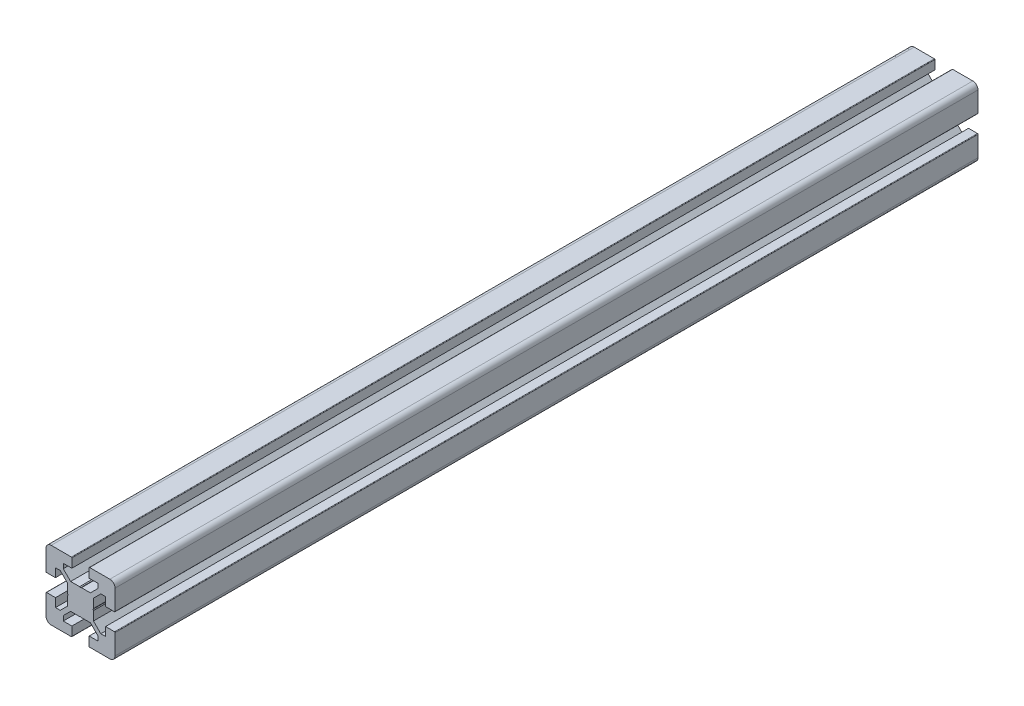
from build123d import *

# Parameters (mm, degrees)
EXTRUDE_1_DEPTH = 500


with BuildPart() as part:
    # Model → ﾎﾞｽ - 押し出し1 (new body)
    with BuildSketch(Plane.XY):
        with BuildLine():
            Line((69.700000053, 55.000000195), (64.500000711, 55.000000195))
            Line((64.500000711, 55.000000195), (64.500000711, 60.000002187))
            Line((64.500000711, 60.000002187), (61.76777021, 60.000002187))
            Line((61.76777021, 60.000002187), (57.500000584, 55.732232559))
            Line((57.500000584, 55.732232559), (57.500000584, 50.519614724))
            Line((57.500000584, 50.519614724), (57.199999339, 50.000000177))
            Line((57.199999339, 50.000000177), (57.500000584, 49.48038563))
            Line((57.500000584, 49.48038563), (57.500000584, 44.267767795))
            Line((57.500000584, 44.267767795), (61.76777021, 39.999998167))
            Line((61.76777021, 39.999998167), (64.500000711, 39.999998167))
            Line((64.500000711, 39.999998167), (64.500000711, 45.000000159))
            Line((64.500000711, 45.000000159), (69.700000053, 45.000000159))
            ThreePointArc((69.700000053, 45.000000159), (69.9121326, 44.912131981), (70.000000778, 44.699999434))
            Line((70.000000778, 44.699999434), (70.000000778, 33.000000332))
            ThreePointArc((70.000000778, 33.000000332), (69.121321121, 30.878679988), (67.000000778, 30.000000332))
            Line((67.000000778, 30.000000332), (55.300001675, 30.000000332))
            ThreePointArc((55.300001675, 30.000000332), (55.087869129, 30.08786851), (55.000000951, 30.300001056))
            Line((55.000000951, 30.300001056), (55.000000951, 35.500000399))
            Line((55.000000951, 35.500000399), (60.000002943, 35.500000399))
            Line((60.000002943, 35.500000399), (60.000002943, 38.232230899))
            Line((60.000002943, 38.232230899), (55.732233316, 42.500000527))
            Line((55.732233316, 42.500000527), (50.519615481, 42.500000527))
            Line((50.519615481, 42.500000527), (50.000000936, 42.800001775))
            Line((50.000000936, 42.800001775), (49.480386391, 42.500000527))
            Line((49.480386391, 42.500000527), (44.267768556, 42.500000527))
            Line((44.267768556, 42.500000527), (39.999998929, 38.232230899))
            Line((39.999998929, 38.232230899), (39.999998929, 35.500000399))
            Line((39.999998929, 35.500000399), (45.000000921, 35.500000399))
            Line((45.000000921, 35.500000399), (45.000000921, 30.300001056))
            ThreePointArc((45.000000921, 30.300001056), (44.912132743, 30.08786851), (44.700000197, 30.000000332))
            Line((44.700000197, 30.000000332), (33.000001094, 30.000000332))
            ThreePointArc((33.000001094, 30.000000332), (30.87868075, 30.878679988), (30.000001094, 33.000000332))
            Line((30.000001094, 33.000000332), (30.000001094, 44.699999434))
            ThreePointArc((30.000001094, 44.699999434), (30.087869272, 44.912131981), (30.300001819, 45.000000159))
            Line((30.300001819, 45.000000159), (35.500001161, 45.000000159))
            Line((35.500001161, 45.000000159), (35.500001161, 39.999998167))
            Line((35.500001161, 39.999998167), (38.232231661, 39.999998167))
            Line((38.232231661, 39.999998167), (42.499994889, 44.267761396))
            Line((42.499994889, 44.267761396), (42.499994889, 49.48038563))
            Line((42.499994889, 49.48038563), (42.799996134, 50.000000177))
            Line((42.799996134, 50.000000177), (42.499994889, 50.519614724))
            Line((42.499994889, 50.519614724), (42.499994889, 55.732238958))
            Line((42.499994889, 55.732238958), (38.232231661, 60.000002187))
            Line((38.232231661, 60.000002187), (35.500001161, 60.000002187))
            Line((35.500001161, 60.000002187), (35.500001161, 55.000000195))
            Line((35.500001161, 55.000000195), (30.300001819, 55.000000195))
            ThreePointArc((30.300001819, 55.000000195), (30.087869272, 55.087868373), (30.000001094, 55.30000092))
            Line((30.000001094, 55.30000092), (30.000001094, 67.000000023))
            ThreePointArc((30.000001094, 67.000000023), (30.87868075, 69.121320366), (33.000001094, 70.000000023))
            Line((33.000001094, 70.000000023), (44.700000197, 70.000000023))
            ThreePointArc((44.700000197, 70.000000023), (44.912132743, 69.912131845), (45.000000921, 69.699999298))
            Line((45.000000921, 69.699999298), (45.000000921, 64.499999956))
            Line((45.000000921, 64.499999956), (39.999998929, 64.499999956))
            Line((39.999998929, 64.499999956), (39.999998929, 61.767769455))
            Line((39.999998929, 61.767769455), (44.267768556, 57.499999827))
            Line((44.267768556, 57.499999827), (49.480386391, 57.499999827))
            Line((49.480386391, 57.499999827), (50.000000936, 57.199998579))
            Line((50.000000936, 57.199998579), (50.519615481, 57.499999827))
            Line((50.519615481, 57.499999827), (55.732233316, 57.499999827))
            Line((55.732233316, 57.499999827), (60.000002943, 61.767769455))
            Line((60.000002943, 61.767769455), (60.000002943, 64.499999956))
            Line((60.000002943, 64.499999956), (55.000000951, 64.499999956))
            Line((55.000000951, 64.499999956), (55.000000951, 69.699999298))
            ThreePointArc((55.000000951, 69.699999298), (55.087869129, 69.912131845), (55.300001675, 70.000000023))
            Line((55.300001675, 70.000000023), (67.000000778, 70.000000023))
            ThreePointArc((67.000000778, 70.000000023), (69.121321121, 69.121320366), (70.000000778, 67.000000023))
            Line((70.000000778, 67.000000023), (70.000000778, 55.30000092))
            ThreePointArc((70.000000778, 55.30000092), (69.9121326, 55.087868373), (69.700000053, 55.000000195))
        make_face()
    extrude(amount=-EXTRUDE_1_DEPTH)


solid = part.part
